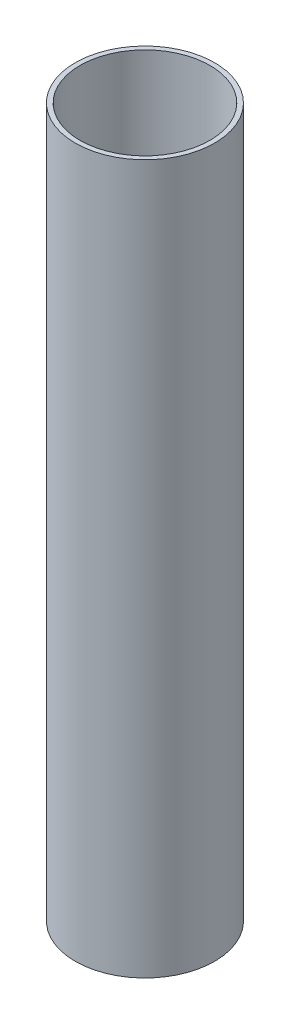
from build123d import *

# Parameters (mm, degrees)
SKETCH1_R           = 29.5
SKETCH1_R_2         = 27.5
BOSS_EXTRUDE1_DEPTH = 300


with BuildPart() as part:
    # Sketch1 → Boss-Extrude1 (new body)
    with BuildSketch(Plane(origin=(0, 0, 0), x_dir=(1, 0, 0), z_dir=(0, 1, 0))):
        Circle(SKETCH1_R)
        Circle(SKETCH1_R_2, mode=Mode.SUBTRACT)
    extrude(amount=BOSS_EXTRUDE1_DEPTH)


solid = part.part
